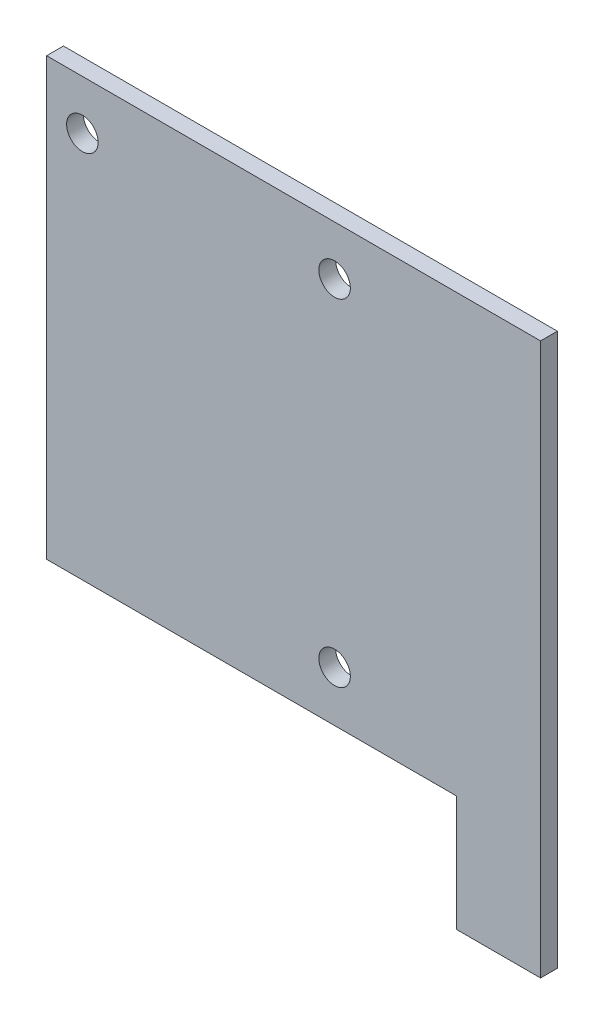
from build123d import *

# Parameters (mm, degrees)
SKETCH_1_R      = 1.5
EXTRUDE_1_DEPTH = 1.6


with BuildPart() as part:
    # 草图1 → 凸台-拉伸1 (new body)
    with BuildSketch(Plane.XY):
        Polygon((15.5, -26.25), (15.5, -15.25), (-23.5, -15.25), (-23.5, 26.25), (23.5, 26.25), (23.5, -26.25), align=None)
        with Locations((3.9, 21.55)):
            Circle(SKETCH_1_R, mode=Mode.SUBTRACT)
        with Locations((3.9, -10.45)):
            Circle(SKETCH_1_R, mode=Mode.SUBTRACT)
        with Locations((-20.1, 21.55)):
            Circle(SKETCH_1_R, mode=Mode.SUBTRACT)
    extrude(amount=EXTRUDE_1_DEPTH)


solid = part.part
